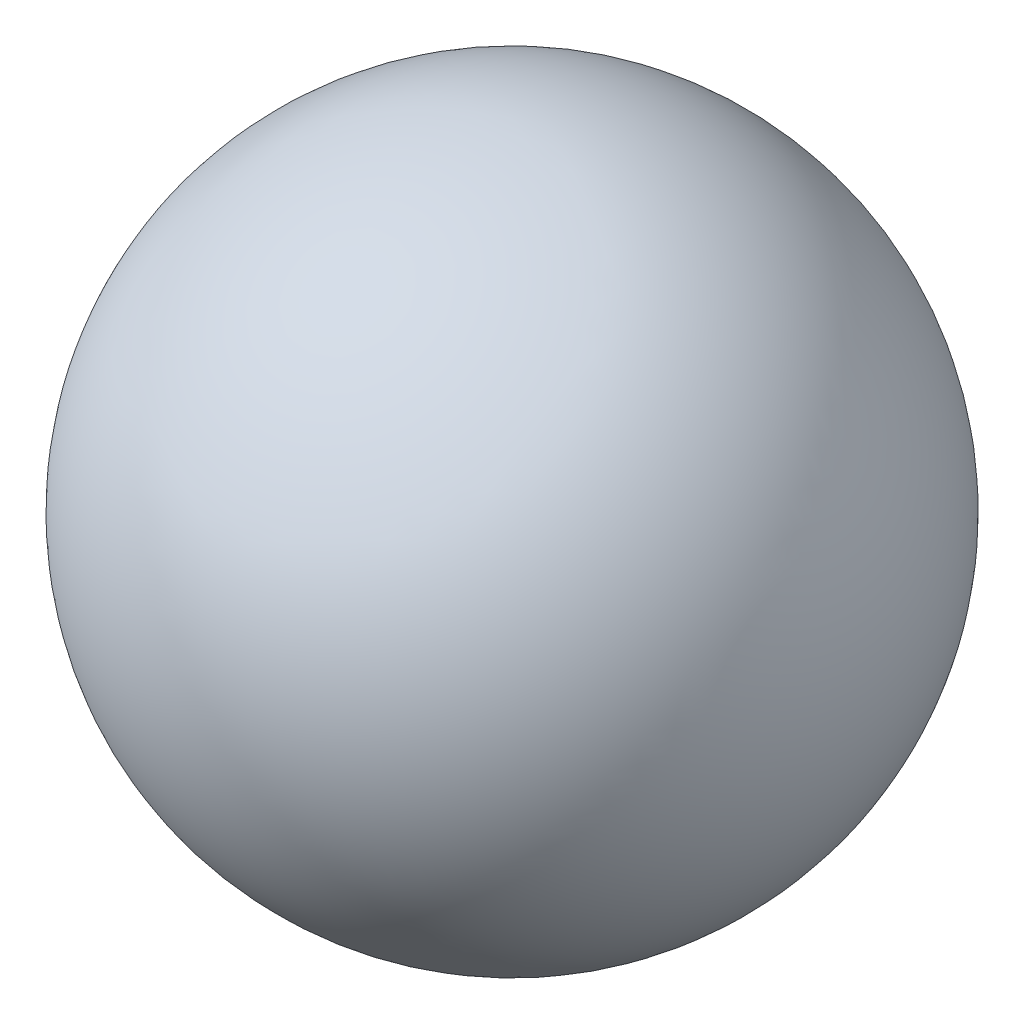
from build123d import *


with BuildPart() as part:
    # RevolveS → Revolve 2 (revolve)
    with BuildSketch(Plane.XY):
        with BuildLine():
            Line((1, 0), (-1, 0))
            ThreePointArc((-1, 0), (0, 1), (1, 0))
        make_face()
    revolve(axis=Axis((1, 0, 0), (-1, 0, 0)))


solid = part.part
